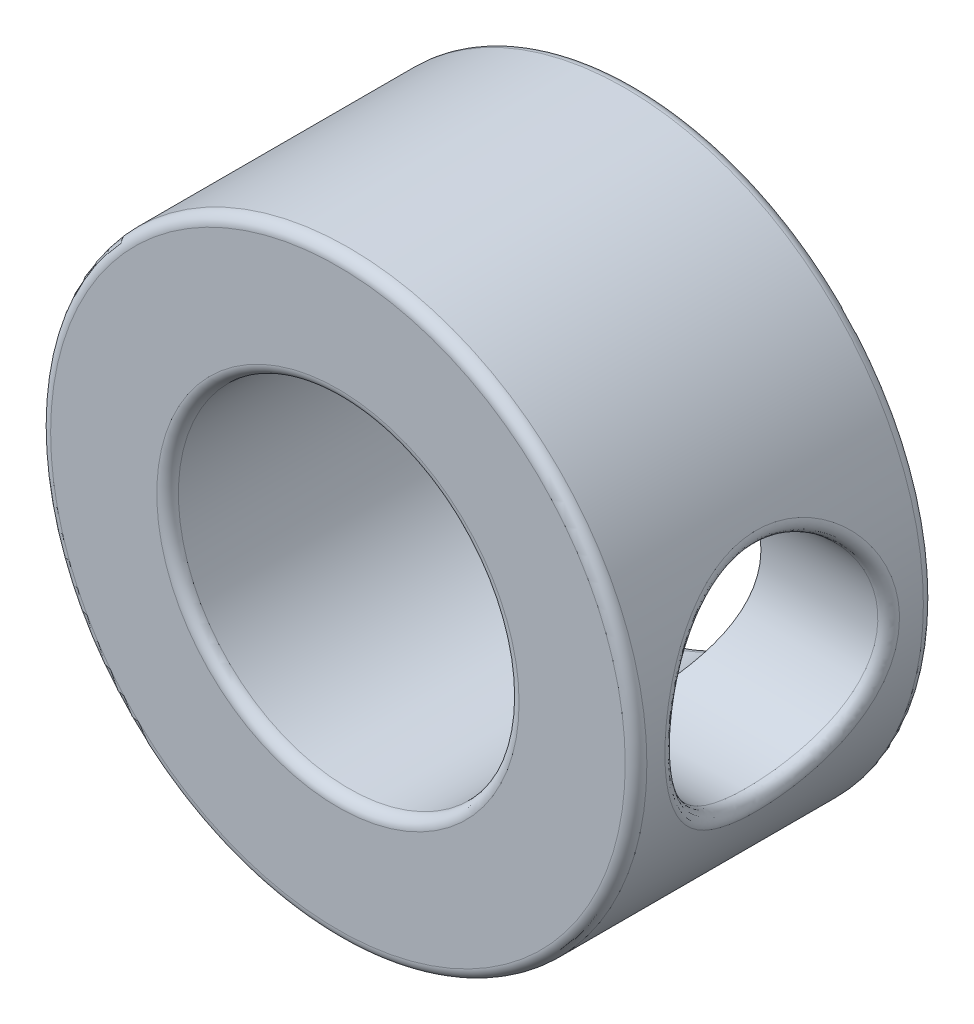
from build123d import *

# Parameters (mm, degrees)
SKETCH2_R           = 7
BOSS_EXTRUDE1_DEPTH = 7
SKETCH3_R           = 4
CUT_EXTRUDE1_DEPTH  = 8
SKETCH4_R           = 2.499999953
CUT_EXTRUDE2_DEPTH  = 8
FILLET1_R           = 0.254


with BuildPart() as part:
    # Sketch2 → Boss-Extrude1 (new body)
    with BuildSketch(Plane.XY):
        Circle(SKETCH2_R)
    extrude(amount=BOSS_EXTRUDE1_DEPTH)

    # Sketch3 → Cut-Extrude1 (cut, through all)
    with BuildSketch(Plane.XY.offset(7)):
        Circle(SKETCH3_R)
    extrude(amount=-CUT_EXTRUDE1_DEPTH, mode=Mode.SUBTRACT)

    # Sketch4 → Cut-Extrude2 (cut, through all)
    with BuildSketch(Plane(origin=(0, 0, 0), x_dir=(0, 0, -1), z_dir=(1, 0, 0))):
        with Locations((-3.5687, 0)):
            Circle(SKETCH4_R)
    extrude(amount=CUT_EXTRUDE2_DEPTH, mode=Mode.SUBTRACT)

    # Fillet1
    fillet1_edges = [part.edges().sort_by_distance(p)[0] for p in [
        (6.538348433, 2.499999953, 3.5687),
        (-7, 0, 0),
        (-7, 0, 7),
        (-4, 0, 0),
        (-4, 0, 7),
    ]]
    fillet(fillet1_edges, radius=FILLET1_R)


solid = part.part
